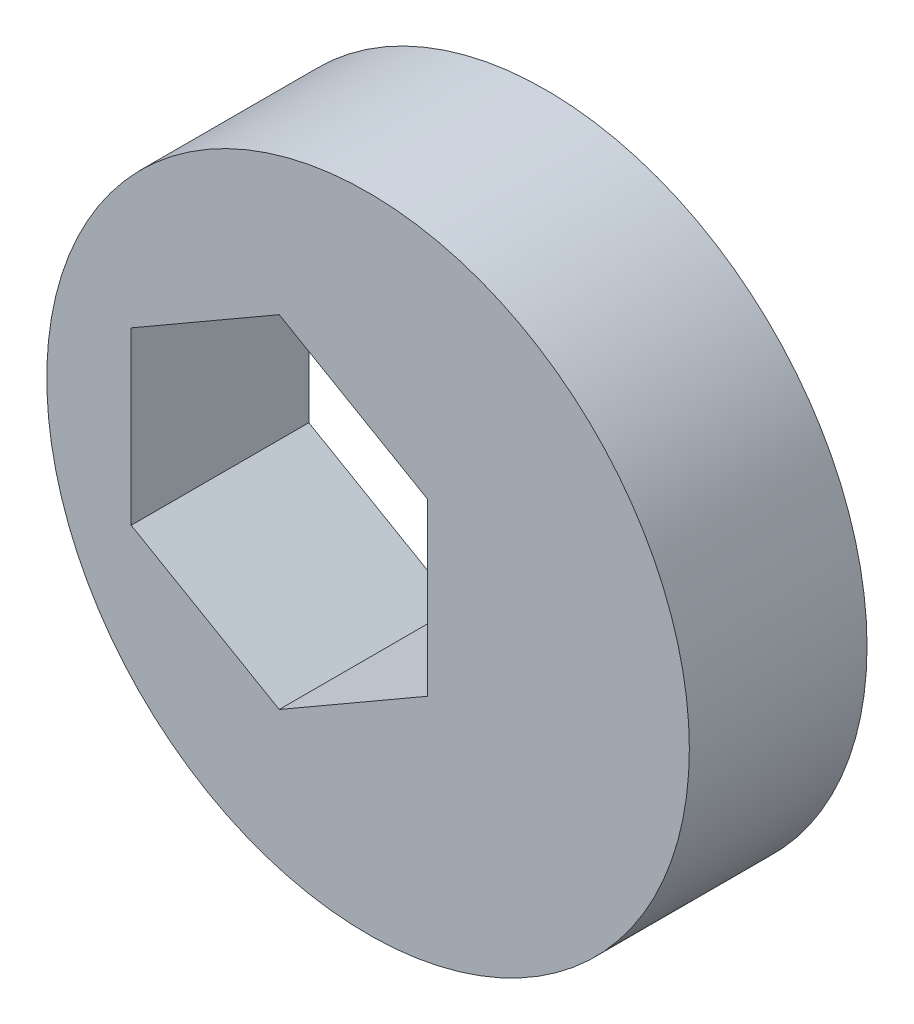
from build123d import *

# Parameters (mm, degrees)
SKETCH1_R           = 10.85
BOSS_EXTRUDE1_DEPTH = 6


with BuildPart() as part:
    # Sketch1 → Boss-Extrude1 (new body)
    with BuildSketch(Plane.XY):
        with Locations((3, 0)):
            Circle(SKETCH1_R)
        Polygon((0, 5.773502692), (-5, 2.886751346), (-5, -2.886751346), (0, -5.773502692), (5, -2.886751346), (5, 2.886751346), align=None, mode=Mode.SUBTRACT)
    extrude(amount=-BOSS_EXTRUDE1_DEPTH)


solid = part.part
